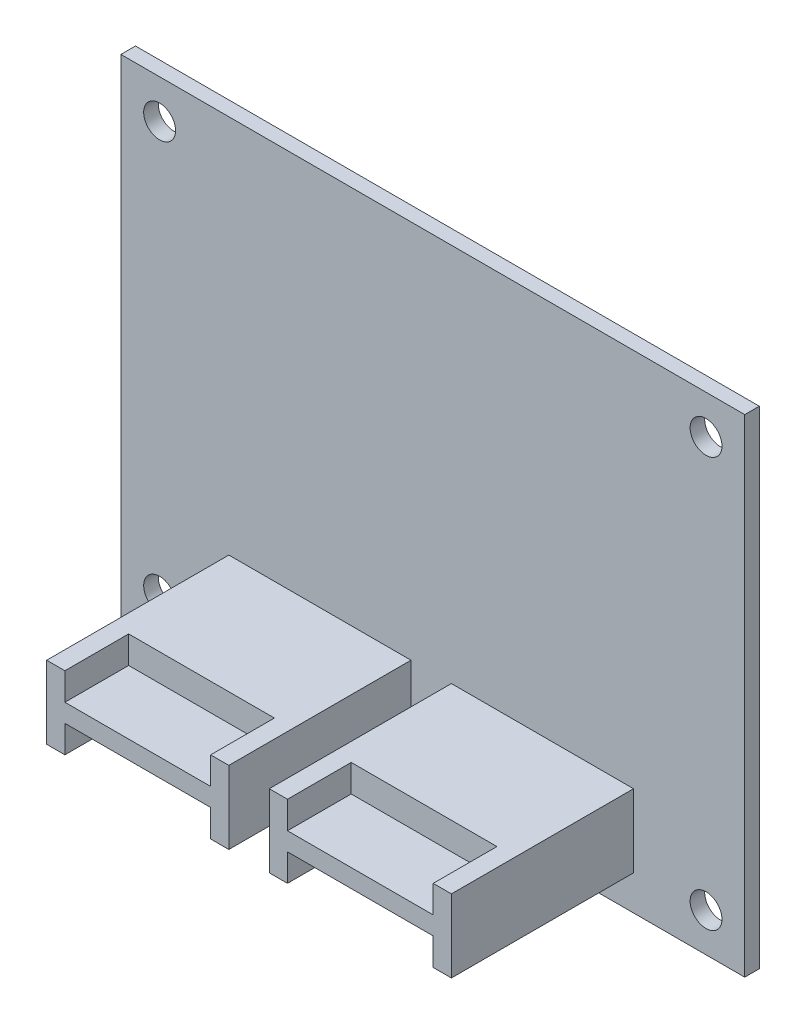
from build123d import *

# Parameters (mm, degrees)
SKETCH1_W           = 68.5
SKETCH1_H           = 53.5
SKETCH1_R           = 1.75
BOSS_EXTRUDE1_DEPTH = 0.8
SKETCH2_W           = 20
SKETCH2_H           = 8
BOSS_EXTRUDE2_DEPTH = 20
SKETCH3_W           = 16
SKETCH3_H           = 3
CUT_EXTRUDE1_DEPTH  = 7


with BuildPart() as part:
    # Sketch1 → Boss-Extrude1 (new body, symmetric)
    with BuildSketch(Plane.XY):
        Rectangle(SKETCH1_W, SKETCH1_H)
        with Locations((-30, 22.5)):
            Circle(SKETCH1_R, mode=Mode.SUBTRACT)
        with Locations((30, 22.5)):
            Circle(SKETCH1_R, mode=Mode.SUBTRACT)
        with Locations((-30, -22.5)):
            Circle(SKETCH1_R, mode=Mode.SUBTRACT)
        with Locations((30, -22.5)):
            Circle(SKETCH1_R, mode=Mode.SUBTRACT)
    extrude(amount=BOSS_EXTRUDE1_DEPTH, both=True)

    # Sketch2 → Boss-Extrude2 (add)
    with BuildSketch(Plane.XY.offset(0.8)):
        with Locations((-12.399398806, -18.931036611)):
            Rectangle(SKETCH2_W, SKETCH2_H)
        with Locations((12.039766375, -18.931036611)):
            Rectangle(SKETCH2_W, SKETCH2_H)
    extrude(amount=BOSS_EXTRUDE2_DEPTH)

    # Sketch3 → Cut-Extrude1 (cut)
    with BuildSketch(Plane.XY.offset(20.8)):
        with Locations((-12.399398806, -16.431036611)):
            Rectangle(SKETCH3_W, SKETCH3_H)
        with Locations((-12.399398806, -21.431036611)):
            Rectangle(SKETCH3_W, SKETCH3_H)
        with Locations((12.039766375, -16.431036611)):
            Rectangle(SKETCH3_W, SKETCH3_H)
        with Locations((12.039766375, -21.431036611)):
            Rectangle(SKETCH3_W, SKETCH3_H)
    extrude(amount=-CUT_EXTRUDE1_DEPTH, mode=Mode.SUBTRACT)


solid = part.part
